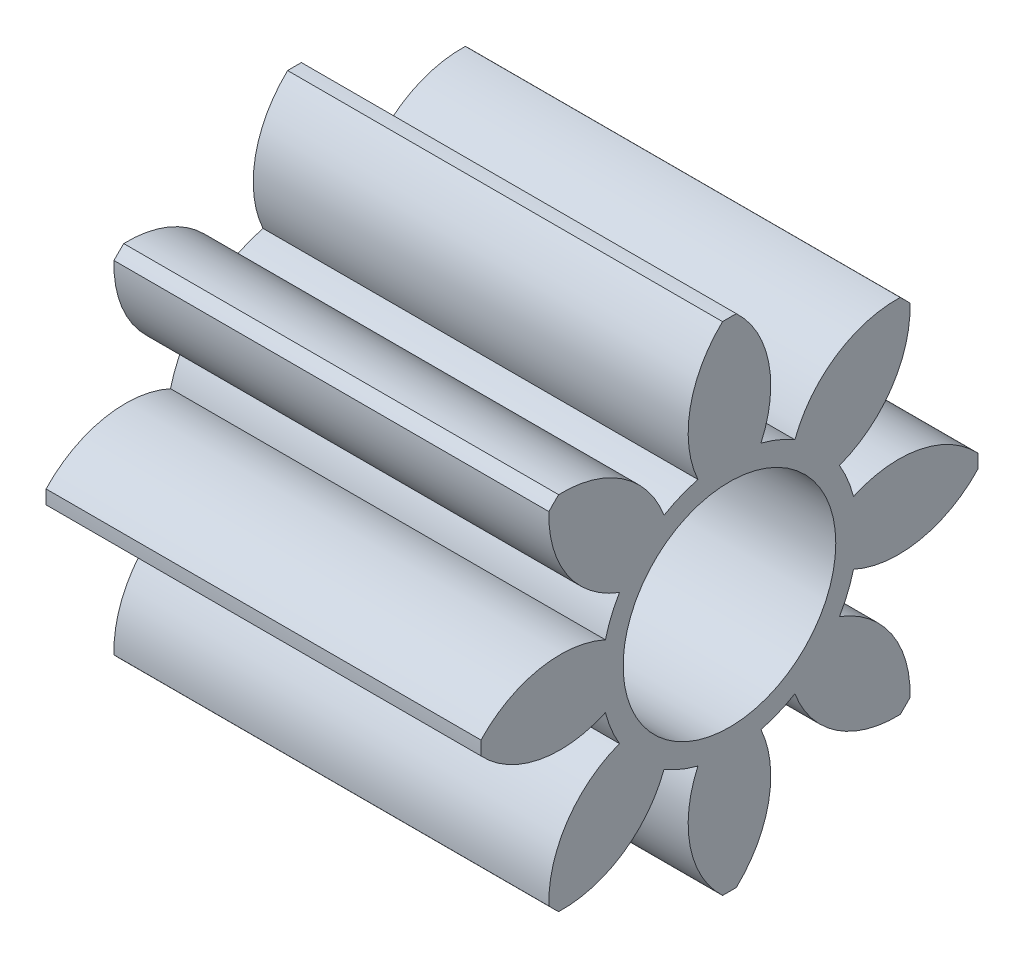
from build123d import *

# Parameters (mm, degrees)
SKETCH1_R           = 2.286
SKETCH1_R_2         = 0.9779
BOSS_EXTRUDE1_DEPTH = 4
CUT_EXTRUDE1_DEPTH  = 5
CIRPATTERN1_COUNT   = 8


with BuildPart() as part:
    # Sketch1 → Boss-Extrude1 (new body)
    with BuildSketch(Plane(origin=(0, 0, 0), x_dir=(0, 0, -1), z_dir=(1, 0, 0))):
        Circle(SKETCH1_R)
        Circle(SKETCH1_R_2, mode=Mode.SUBTRACT)
    extrude(amount=BOSS_EXTRUDE1_DEPTH)

    # Sketch2 → Cut-Extrude1 (cut, through all)
    with BuildSketch(Plane(origin=(4, 0, 0), x_dir=(0, 0, -1), z_dir=(1, 0, 0))):
        with BuildLine():
            ThreePointArc((-1.140932588, 0.28986551), (-1.825366269, 0.342648296), (-2.382567636, -0.058303225))
            ThreePointArc((-2.382567636, -0.058303225), (-2.201864435, 0.912042112), (-1.643503126, 1.725956338))
            ThreePointArc((-1.643503126, 1.725956338), (-1.5330178, 1.048439933), (-1.011727037, 0.601795302))
            ThreePointArc((-1.011727037, 0.601795302), (-1.087571108, 0.450486703), (-1.140932588, 0.28986551))
        make_face()
    cut_extrude1 = extrude(amount=-CUT_EXTRUDE1_DEPTH, mode=Mode.SUBTRACT)

    # CirPattern1: Cut-Extrude1 ×8 about axis
    cirpattern1_axis = Axis((0, 0, 0), (1, 0, 0))
    for i in range(1, CIRPATTERN1_COUNT):
        add(cut_extrude1.rotate(cirpattern1_axis, i * 360 / CIRPATTERN1_COUNT), mode=Mode.SUBTRACT)


solid = part.part
